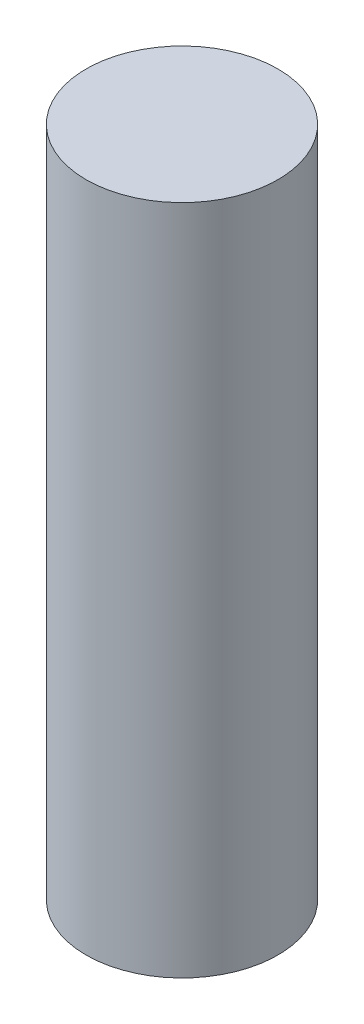
from build123d import *

# Parameters (mm, degrees)
SKETCH1_R           = 5
BOSS_EXTRUDE1_DEPTH = 17.5


with BuildPart() as part:
    # Sketch1 → Boss-Extrude1 (new body, symmetric)
    with BuildSketch(Plane(origin=(0, 0, 0), x_dir=(1, 0, 0), z_dir=(0, 1, 0))):
        Circle(SKETCH1_R)
    extrude(amount=BOSS_EXTRUDE1_DEPTH, both=True)


solid = part.part
